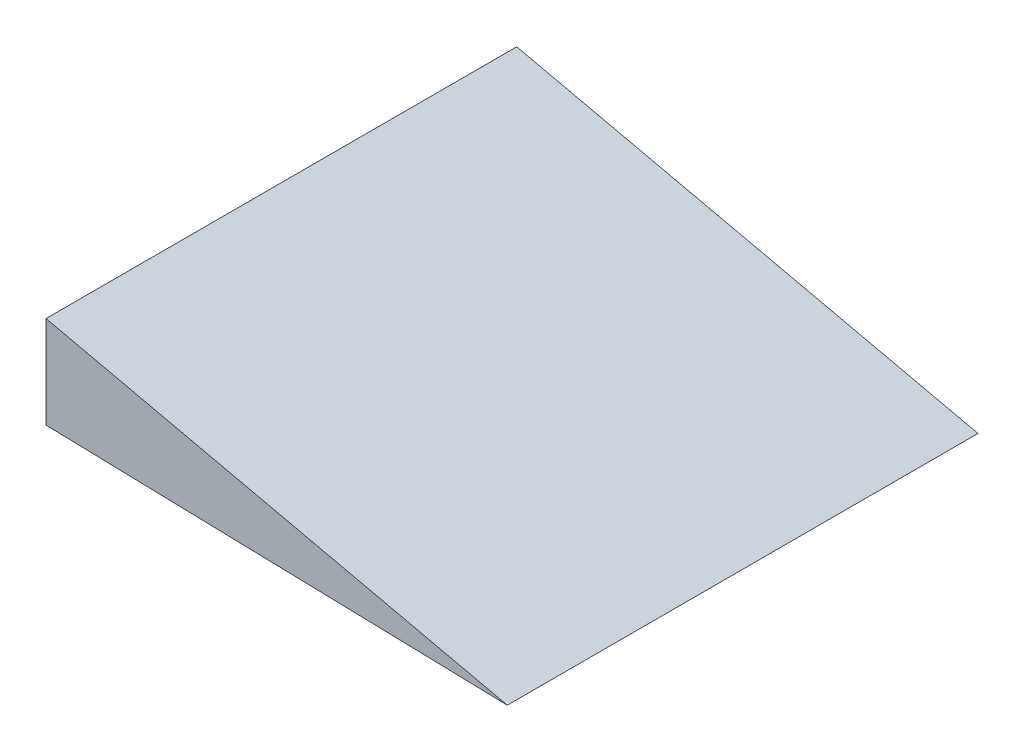
from build123d import *

# Parameters (mm, degrees)
RESSALTO_EXTRUS_O1_DEPTH = 102
ESBO_O3_R                = 1.5
CORTE_EXTRUS_O2_DEPTH    = 10


with BuildPart() as part:
    # Esboço1 → Ressalto-extrusão1 (new body)
    with BuildSketch(Plane.XY):
        Polygon((-21.132279289, 13.382352941), (-21.132279289, -6.617647059), (78.834377283, -9.19981162), align=None)
    extrude(amount=RESSALTO_EXTRUS_O1_DEPTH)

    # Esboço3 → Corte-extrusão2 (cut)
    with BuildSketch(Plane(origin=(-0.184911664, -7.158722975, 0), x_dir=(0.999666566, -0.025821646, 0), z_dir=(-0.025821646, -0.999666566, 0))):
        with Locations((4.045645474, 25)):
            Circle(ESBO_O3_R)
        with Locations((4.045645474, 77)):
            Circle(ESBO_O3_R)
    extrude(amount=-CORTE_EXTRUS_O2_DEPTH, mode=Mode.SUBTRACT)


solid = part.part
